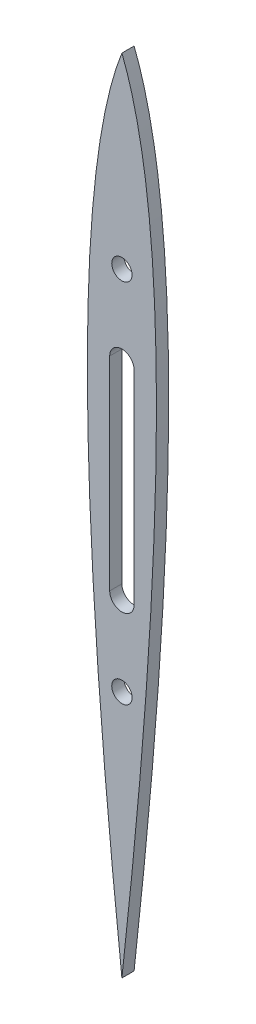
from build123d import *

# Parameters (mm, degrees)
SKETCH1_R          = 3.175
MAIN_EXTRUDE_DEPTH = 3.81


with BuildPart() as part:
    # Sketch1 → Main extrude (new body)
    with BuildSketch(Plane.XY):
        with BuildLine():
            add(Edge.make_bspline(
                [(0, 140.978035645), (3.918482074, 131.156065717), (8.169378172, 106.05556313), (10.242574642, 81.433345605), (11.145665597, 45.040166844), (8.163737965, -35.508846412), (0, -109.12531842)],
                knots=[0.045526815, 0.045526815, 0.045526815, 0.20753057, 0.315533073, 0.423535576, 0.585539331, 0.909546841, 0.909546841, 0.909546841], degree=2))
            add(Edge.make_bspline(
                [(0, -109.12531842), (-8.163737965, -35.508846412), (-11.145665597, 45.040166844), (-10.242574642, 81.433345605), (-8.169378172, 106.05556313), (-3.918482074, 131.156065717), (0, 140.978035645)],
                knots=[0.045526815, 0.045526815, 0.045526815, 0.369534325, 0.53153808, 0.639540583, 0.747543086, 0.909546841, 0.909546841, 0.909546841], degree=2))
        make_face()
        with Locations(Location((0, 82.55, 0), (0, 0, 180))):
            Circle(SKETCH1_R, mode=Mode.SUBTRACT)
        with Locations(Location((0, -31.75, 0), (0, 0, 180))):
            Circle(SKETCH1_R, mode=Mode.SUBTRACT)
        with BuildLine():
            Line((3.81, 57.15), (3.81, -6.35))
            ThreePointArc((3.81, -6.35), (0, -10.16), (-3.81, -6.35))
            Line((-3.81, -6.35), (-3.81, 57.15))
            ThreePointArc((-3.81, 57.15), (0, 60.96), (3.81, 57.15))
        make_face(mode=Mode.SUBTRACT)
    extrude(amount=MAIN_EXTRUDE_DEPTH)


solid = part.part
